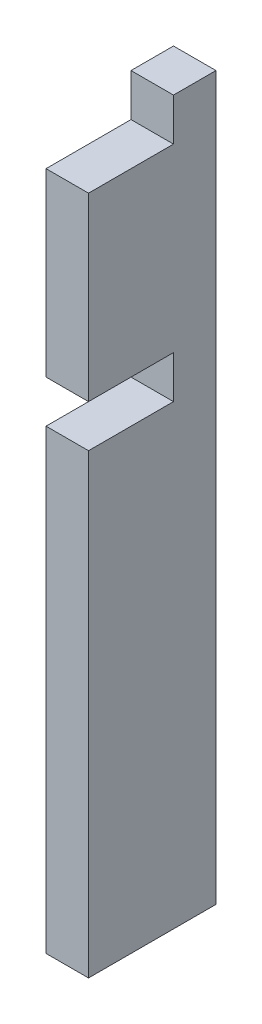
from build123d import *

# Parameters (mm, degrees)
SKETCH1_W           = 19.05
SKETCH1_H           = 107.95
BOSS_EXTRUDE1_DEPTH = 3.175
SKETCH2_W           = 12.7
SKETCH2_H           = 6.35
CUT_EXTRUDE1_DEPTH  = 7.35


with BuildPart() as part:
    # Sketch1 → Boss-Extrude1 (new body, symmetric)
    with BuildSketch(Plane(origin=(0, 0, 0), x_dir=(0, 0, -1), z_dir=(1, 0, 0))):
        Rectangle(SKETCH1_W, SKETCH1_H)
    extrude(amount=BOSS_EXTRUDE1_DEPTH, both=True)

    # Sketch2 → Cut-Extrude1 (cut, through all)
    with BuildSketch(Plane(origin=(3.175, 0, 0), x_dir=(0, 0, -1), z_dir=(1, 0, 0))):
        with Locations((-3.175, 50.8)):
            Rectangle(SKETCH2_W, SKETCH2_H)
        with Locations((-3.175, 17.4625)):
            Rectangle(SKETCH2_W, SKETCH2_H)
    extrude(amount=-CUT_EXTRUDE1_DEPTH, mode=Mode.SUBTRACT)


solid = part.part
